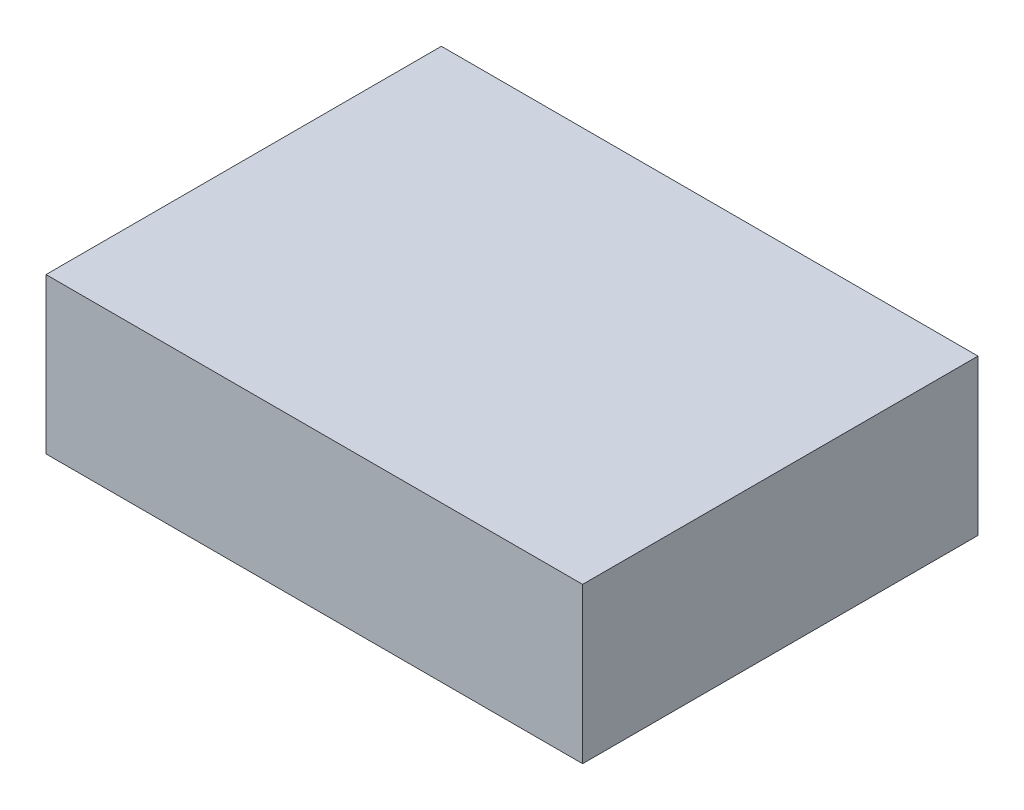
from build123d import *

# Parameters (mm, degrees)
SKETCH_1_W   = 950
SKETCH_1_H   = 700
ARM600_DEPTH = 275


with BuildPart() as part:
    # Эскиз1 → Габарит ARM600 (new body)
    with BuildSketch(Plane(origin=(0, 0, 0), x_dir=(1, 0, 0), z_dir=(0, 1, 0))):
        Rectangle(SKETCH_1_W, SKETCH_1_H)
    extrude(amount=ARM600_DEPTH)


solid = part.part
